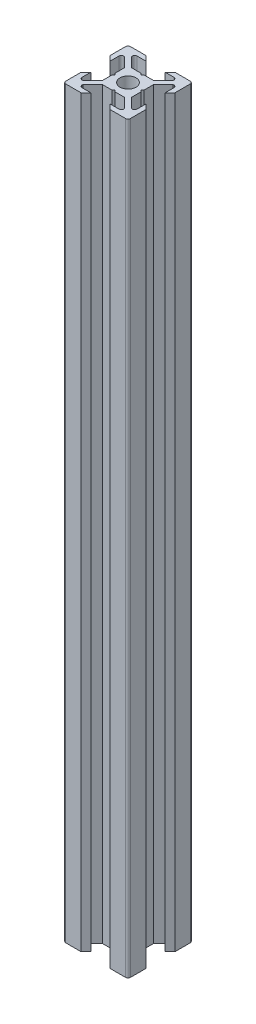
from build123d import *

# Parameters (mm, degrees)
ESQUISSE1_R      = 2.5
EXTRUSION1_DEPTH = 230
CONG_1_R         = 0.75


with BuildPart() as part:
    # Esquisse1 → Extrusion1 (new body)
    with BuildSketch(Plane(origin=(0, 0, 0), x_dir=(1, 0, 0), z_dir=(0, 1, 0))):
        Polygon((0, 4), (-0.5, 4.5), (-3.439339828, 4.5), (-6.439339828, 7.5), (-6.439339828, 8.5), (-3, 8.5), (-4.5, 10), (-10, 10), (-10, 4.5), (-8.5, 3), (-8.5, 6.439339828), (-7.5, 6.439339828), (-4.5, 3.439339828), (-4.5, 0.5), (-4, 0), (-4.5, -0.5), (-4.5, -3.439339828), (-7.5, -6.439339828), (-8.5, -6.439339828), (-8.5, -3), (-10, -4.5), (-10, -10), (-4.5, -10), (-3, -8.5), (-6.439339828, -8.5), (-6.439339828, -7.5), (-3.439339828, -4.5), (-0.5, -4.5), (0, -4), (0.5, -4.5), (3.439339828, -4.5), (6.439339828, -7.5), (6.439339828, -8.5), (3, -8.5), (4.5, -10), (10, -10), (10, -4.5), (8.5, -3), (8.5, -6.439339828), (7.5, -6.439339828), (4.5, -3.439339828), (4.5, -0.5), (4, 0), (4.5, 0.5), (4.5, 3.439339828), (7.5, 6.439339828), (8.5, 6.439339828), (8.5, 3), (10, 4.5), (10, 10), (4.5, 10), (3, 8.5), (6.439339828, 8.5), (6.439339828, 7.5), (3.439339828, 4.5), (0.5, 4.5), align=None)
        Circle(ESQUISSE1_R, mode=Mode.SUBTRACT)
    extrude(amount=EXTRUSION1_DEPTH)

    # Congé1
    cong_1_edges = [part.edges().sort_by_distance(p)[0] for p in [
        (6.439339828, 115, -8.5),
        (10, 115, -10),
        (8.5, 115, -6.439339828),
        (8.5, 115, 6.439339828),
        (10, 115, 10),
        (6.439339828, 115, 8.5),
        (-6.439339828, 115, 8.5),
        (-10, 115, 10),
        (-8.5, 115, 6.439339828),
        (-8.5, 115, -6.439339828),
        (-10, 115, -10),
        (-6.439339828, 115, -8.5),
    ]]
    fillet(cong_1_edges, radius=CONG_1_R)


solid = part.part
